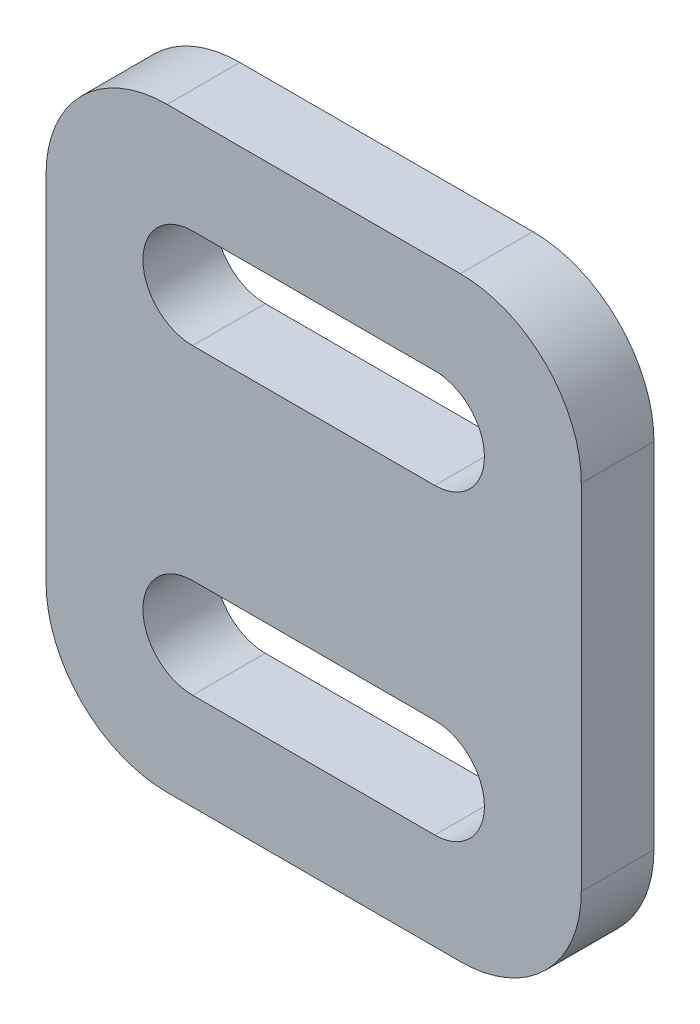
from build123d import *

# Parameters (mm, degrees)
ESBO_O1_W                = 22.1
ESBO_O1_H                = 24.6
RESSALTO_EXTRUS_O1_DEPTH = 3
FILETE1_R                = 5


with BuildPart() as part:
    # Esboço1 → Ressalto-extrusão1 (new body)
    with BuildSketch(Plane.XY):
        with Locations((27.12188209, 20.25)):
            Rectangle(ESBO_O1_W, ESBO_O1_H)
        with BuildLine():
            Line((22.12188209, 28.55), (32.12188209, 28.55))
            ThreePointArc((32.12188209, 28.55), (34.17188209, 26.5), (32.12188209, 24.45))
            Line((32.12188209, 24.45), (22.12188209, 24.45))
            ThreePointArc((22.12188209, 24.45), (20.07188209, 26.5), (22.12188209, 28.55))
        make_face(mode=Mode.SUBTRACT)
        with BuildLine():
            Line((22.12188209, 16.05), (32.12188209, 16.05))
            ThreePointArc((32.12188209, 16.05), (34.17188209, 14), (32.12188209, 11.95))
            Line((32.12188209, 11.95), (22.12188209, 11.95))
            ThreePointArc((22.12188209, 11.95), (20.07188209, 14), (22.12188209, 16.05))
        make_face(mode=Mode.SUBTRACT)
    extrude(amount=RESSALTO_EXTRUS_O1_DEPTH)

    # Filete1
    filete1_edges = [part.edges().sort_by_distance(p)[0] for p in [
        (16.07188209, 32.55, 1.5),
        (38.17188209, 32.55, 1.5),
        (38.17188209, 7.95, 1.5),
        (16.07188209, 7.95, 1.5),
    ]]
    fillet(filete1_edges, radius=FILETE1_R)


solid = part.part
